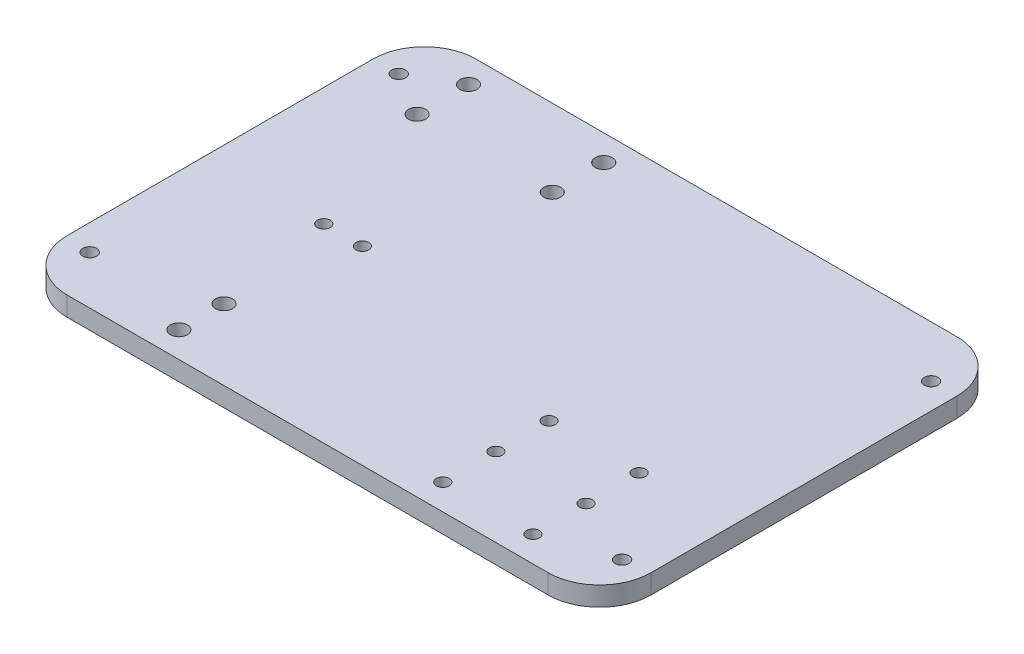
from build123d import *

# Parameters (mm, degrees)
SKETCH1_W                       = 287.9979
SKETCH1_H                       = 201.6125
BOSS_EXTRUDE1_DEPTH             = 9.525
FILLET2_R                       = 25.4
F_1_4_CLEARANCE_HOLE1_D         = 6.7564
F_1_4_CLEARANCE_HOLE1_DEPTH     = 21.59
F_1_4_CLEARANCE_HOLE1_TIP       = 2.029827343
F_5_16_CLEARANCE_HOLE1_D        = 8.4328
F_1_4_0_25_DIAMETER_HOLE2_D     = 6.35
F_1_4_0_25_DIAMETER_HOLE2_DEPTH = 21.59
F_1_4_0_25_DIAMETER_HOLE2_TIP   = 1.907732465


with BuildPart() as part:
    # Sketch1 → Boss-Extrude1 (new body)
    with BuildSketch(Plane(origin=(0, 0, 0), x_dir=(1, 0, 0), z_dir=(0, 1, 0))):
        Rectangle(SKETCH1_W, SKETCH1_H)
    extrude(amount=BOSS_EXTRUDE1_DEPTH)

    # Fillet2
    fillet2_edges = [part.edges().sort_by_distance(p)[0] for p in [
        (143.99895, 4.7625, 100.80625),
        (-143.99895, 4.7625, 100.80625),
        (-143.99895, 4.7625, -100.80625),
        (143.99895, 4.7625, -100.80625),
    ]]
    fillet(fillet2_edges, radius=FILLET2_R)

    # 1/4 Clearance Hole1
    with Locations(Plane(origin=(0, 9.525, 0), x_dir=(1, 0, 0), z_dir=(0, 1, 0))):
        with Locations((-131.29895, 75.40625), (131.29895, 75.40625), (131.29895, -76.99375), (-131.29895, -76.99375)):
            Hole(F_1_4_CLEARANCE_HOLE1_D / 2, depth=F_1_4_CLEARANCE_HOLE1_DEPTH)
            with Locations((0, 0, -(F_1_4_CLEARANCE_HOLE1_DEPTH + F_1_4_CLEARANCE_HOLE1_TIP / 2))):  # 118° drill point
                Cone(0, F_1_4_CLEARANCE_HOLE1_D / 2, F_1_4_CLEARANCE_HOLE1_TIP, mode=Mode.SUBTRACT)

    # 5/16 Clearance Hole1 (through all)
    with Locations(Plane(origin=(0, 0, 0), x_dir=(-1, 0, 0), z_dir=(0, -1, 0))):
        with Locations((76.2, -88.10625), (76.2, -65.88125), (42.857421778, 88.10625), (109.542578222, 62.70625), (42.857421778, 62.70625), (109.542578222, 88.10625)):
            Hole(F_5_16_CLEARANCE_HOLE1_D / 2)

    # 1/4 (0.25) Diameter Hole2
    with Locations(Plane(origin=(0, 9.525, 0), x_dir=(1, 0, 0), z_dir=(0, 1, 0))):
        with Locations((53.975, -35.71875), (98.425, -35.71875), (98.425, -61.9125), (98.425, -88.10625), (53.975, -88.10625), (53.975, -61.9125), (-66.675, -7.14375), (-85.725, -7.14375)):
            Hole(F_1_4_0_25_DIAMETER_HOLE2_D / 2, depth=F_1_4_0_25_DIAMETER_HOLE2_DEPTH)
            with Locations((0, 0, -(F_1_4_0_25_DIAMETER_HOLE2_DEPTH + F_1_4_0_25_DIAMETER_HOLE2_TIP / 2))):  # 118° drill point
                Cone(0, F_1_4_0_25_DIAMETER_HOLE2_D / 2, F_1_4_0_25_DIAMETER_HOLE2_TIP, mode=Mode.SUBTRACT)


solid = part.part
